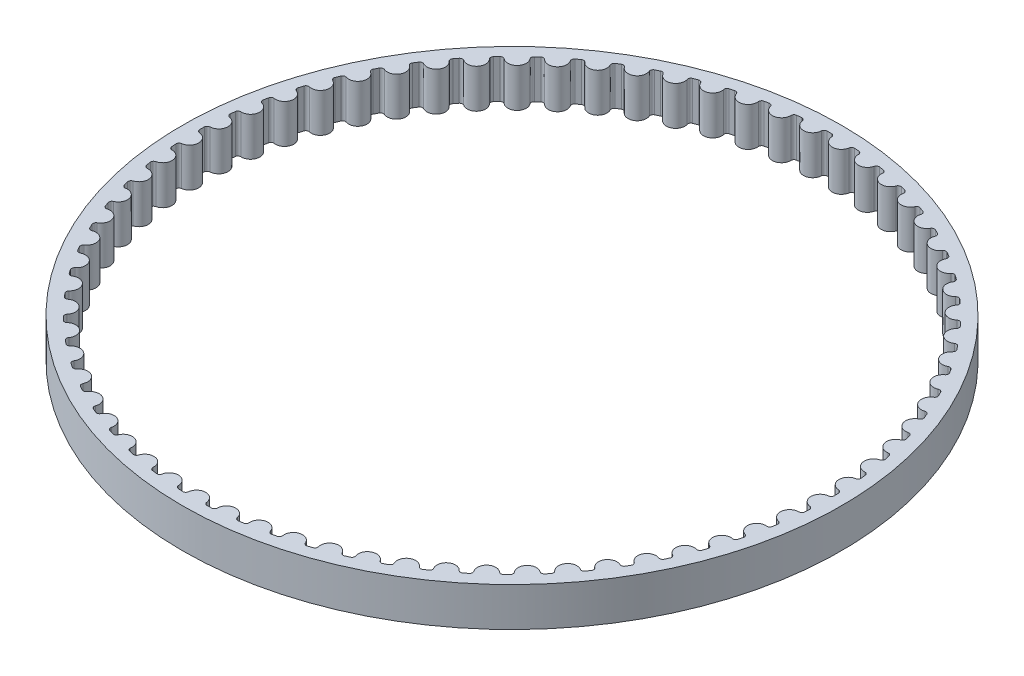
from build123d import *

# Parameters (mm, degrees)
SKETCH1_R           = 33.82407322
BOSS_EXTRUDE1_DEPTH = 4


with BuildPart() as part:
    # Sketch1 → Boss-Extrude1 (new body)
    with BuildSketch(Plane(origin=(0, 0, 0), x_dir=(1, 0, 0), z_dir=(0, 1, 0))):
        Circle(SKETCH1_R)
        with BuildLine():
            ThreePointArc((-1.716913826, -32.518780291), (-1.482140739, -32.530326213), (-1.247290427, -32.540177186))
            ThreePointArc((-1.247290427, -32.540177186), (-1.040267467, -32.467567313), (-0.938533524, -32.273194207))
            ThreePointArc((-0.938533524, -32.273194207), (0, -31.42968704), (0.938533524, -32.273194207))
            ThreePointArc((0.938533524, -32.273194207), (1.040267467, -32.467567313), (1.247290427, -32.540177186))
            ThreePointArc((1.247290427, -32.540177186), (1.482140739, -32.530326213), (1.716913826, -32.518780291))
            ThreePointArc((1.716913826, -32.518780291), (1.916476288, -32.427645647), (2.00011344, -32.224826698))
            ThreePointArc((2.00011344, -32.224826698), (2.858054263, -31.299468897), (3.869403503, -32.054135865))
            ThreePointArc((3.869403503, -32.054135865), (3.988391238, -32.23845249), (4.201159238, -32.291935924))
            ThreePointArc((4.201159238, -32.291935924), (4.434140731, -32.260769685), (4.66689119, -32.227922541))
            ThreePointArc((4.66689119, -32.227922541), (4.857339517, -32.119018298), (4.922186834, -31.909434126))
            ThreePointArc((4.922186834, -31.909434126), (5.692425789, -30.909893498), (6.768210386, -31.569466857))
            ThreePointArc((6.768210386, -31.569466857), (6.903465944, -31.742199696), (7.120215921, -31.776113512))
            ThreePointArc((7.120215921, -31.776113512), (7.349398037, -31.723890259), (7.578197223, -31.670014075))
            ThreePointArc((7.578197223, -31.670014075), (7.757953301, -31.544242647), (7.803473437, -31.329629934))
            ThreePointArc((7.803473437, -31.329629934), (8.479628082, -30.264188986), (9.610933747, -30.823203305))
            ThreePointArc((9.610933747, -30.823203305), (9.761336356, -30.98292104), (9.980272252, -30.996984216))
            ThreePointArc((9.980272252, -30.996984216), (10.203755917, -30.924136688), (10.426707928, -30.849677899))
            ThreePointArc((10.426707928, -30.849677899), (10.59428224, -30.708081467), (10.620098002, -30.490218561))
            ThreePointArc((10.620098002, -30.490218561), (11.196565506, -29.367705874), (12.374017883, -29.821528984))
            ThreePointArc((12.374017883, -29.821528984), (12.538321261, -29.966908141), (12.757628904, -29.961004146))
            ThreePointArc((12.757628904, -29.961004146), (12.973562261, -29.86813598), (13.188819647, -29.773711576))
            ThreePointArc((13.188819647, -29.773711576), (13.342823621, -29.617463454), (13.34872109, -29.398155635))
            ThreePointArc((13.34872109, -29.398155635), (13.820724662, -28.227872701), (15.034567011, -28.572744081))
            ThreePointArc((15.034567011, -28.572744081), (15.211409687, -28.702580005), (15.429271825, -28.67675776))
            ThreePointArc((15.429271825, -28.67675776), (15.635865582, -28.564638492), (15.841644653, -28.451030902))
            ThreePointArc((15.841644653, -28.451030902), (15.980802162, -28.28142581), (15.966732472, -28.062490333))
            ThreePointArc((15.966732472, -28.062490333), (16.33036094, -26.854134486), (17.570534981, -27.087196422))
            ThreePointArc((17.570534981, -27.087196422), (17.758451582, -27.200413251), (17.973062941, -27.154886728))
            ThreePointArc((17.973062941, -27.154886728), (18.168605197, -27.024445413), (18.363200802, -26.892596025))
            ThreePointArc((18.363200802, -26.892596025), (18.486358745, -26.711039365), (18.452438479, -26.494290397))
            ThreePointArc((18.452438479, -26.494290397), (18.704678705, -25.257874454), (19.960907964, -25.377195722))
            ThreePointArc((19.960907964, -25.377195722), (20.158341355, -25.472855306), (20.367923596, -25.408001752))
            ThreePointArc((20.367923596, -25.408001752), (20.550794027, -25.260319268), (20.732593687, -25.111320629))
            ThreePointArc((20.732593687, -25.111320629), (20.838731536, -24.919316836), (20.78524177, -24.706550428))
            ThreePointArc((20.78524177, -24.706550428), (20.924003612, -23.45231972), (22.185878578, -23.456911587))
            ThreePointArc((22.185878578, -23.456911587), (22.391192762, -23.53422126), (22.594009223, -23.450578072))
            ThreePointArc((22.594009223, -23.450578072), (22.762692506, -23.286878162), (22.93018977, -23.121964921))
            ThreePointArc((22.93018977, -23.121964921), (23.018428035, -22.921104999), (22.945812002, -22.7140842))
            ThreePointArc((22.945812002, -22.7140842), (22.969945635, -21.452431679), (24.227010015, -21.342256095))
            ThreePointArc((24.227010015, -21.342256095), (24.438503694, -21.400575244), (24.632873773, -21.298835517))
            ThreePointArc((24.632873773, -21.298835517), (24.785972146, -21.12047465), (24.937779079, -20.94101333))
            ThreePointArc((24.937779079, -20.94101333), (25.00738659, -20.732961668), (24.916246009, -20.533401918))
            ThreePointArc((24.916246009, -20.533401918), (24.825551454, -19.274782033), (26.067388817, -19.050751947))
            ThreePointArc((26.067388817, -19.050751947), (26.283309488, -19.089597323), (26.467622573, -18.970604103))
            ThreePointArc((26.467622573, -18.970604103), (26.603867415, -18.779060234), (26.738726097, -18.586537907))
            ThreePointArc((26.738726097, -18.586537907), (26.789126064, -18.373018487), (26.680216154, -18.1825734))
            ThreePointArc((26.680216154, -18.1825734), (26.475444935, -16.937415473), (27.691765026, -16.601387269))
            ThreePointArc((27.691765026, -16.601387269), (27.910323502, -16.620436986), (28.083052317, -16.485176289))
            ThreePointArc((28.083052317, -16.485176289), (28.201314659, -16.28203661), (28.31810761, -16.078048578))
            ThreePointArc((28.31810761, -16.078048578), (28.348882403, -15.860830688), (28.223105626, -15.681078353))
            ThreePointArc((28.223105626, -15.681078353), (27.905954542, -14.459700154), (29.086678548, -14.014458268))
            ThreePointArc((29.086678548, -14.014458268), (29.306063786, -14.013554473), (29.465777045, -13.863147112))
            ThreePointArc((29.465777045, -13.863147112), (29.565076929, -13.650094903), (29.662836365, -13.436331474))
            ThreePointArc((29.662836365, -13.436331474), (29.673730974, -13.217215051), (29.532129556, -13.049644952))
            ThreePointArc((29.532129556, -13.049644952), (29.10522662, -11.862167205), (30.240570691, -11.311401052))
            ThreePointArc((30.240570691, -11.311401052), (30.458964795, -11.290551235), (30.604339064, -11.126243532))
            ThreePointArc((30.604339064, -11.126243532), (30.68385366, -10.905044211), (30.761769515, -10.683276697))
            ThreePointArc((30.761769515, -10.683276697), (30.752693664, -10.464077407), (30.59644096, -10.310078083))
            ThreePointArc((30.59644096, -10.310078083), (30.063323625, -9.166340603), (31.143879942, -8.514614004))
            ThreePointArc((31.143879942, -8.514614004), (31.35947323, -8.473990934), (31.489303892, -8.297144394))
            ThreePointArc((31.489303892, -8.297144394), (31.548374317, -8.069630888), (31.605800955, -7.841696924))
            ThreePointArc((31.605800955, -7.841696924), (31.57682985, -7.624231123), (31.407220618, -7.485078661))
            ThreePointArc((31.407220618, -7.485078661), (30.772306461, -6.394558817), (31.789121195, -5.647272183))
            ThreePointArc((31.789121195, -5.647272183), (32.000127193, -5.587212475), (32.11333843, -5.399292505))
            ThreePointArc((32.11333843, -5.399292505), (32.151475208, -5.167350062), (32.187936775, -4.935138381))
            ThreePointArc((32.187936775, -4.935138381), (32.139310479, -4.721208058), (31.957750154, -4.598055519))
            ThreePointArc((31.957750154, -4.598055519), (31.226300276, -3.569789701), (32.170947779, -2.733135286))
            ThreePointArc((32.170947779, -2.733135286), (32.375618024, -2.654136614), (32.471271733, -2.456700377))
            ThreePointArc((32.471271733, -2.456700377), (32.488158849, -2.222250946), (32.503353214, -1.987685727))
            ThreePointArc((32.503353214, -1.987685727), (32.43547466, -1.779063577), (32.243467709, -1.672931441))
            ThreePointArc((32.243467709, -1.672931441), (31.421543131, -0.715440185), (32.286195757, 0.20364923))
            ThreePointArc((32.286195757, 0.20364923), (32.482834288, 0.300932259), (32.560137851, 0.506248743))
            ThreePointArc((32.560137851, 0.506248743), (32.555635375, 0.741262442), (32.549436631, 0.976237518))
            ThreePointArc((32.549436631, 0.976237518), (32.462868282, 1.177822786), (32.262005735, 1.266055074))
            ThreePointArc((32.262005735, 1.266055074), (31.356417185, 2.144837695), (32.13391015, 3.138746245))
            ThreePointArc((32.13391015, 3.138746245), (32.320887557, 3.253507513), (32.379200413, 3.465002927))
            ThreePointArc((32.379200413, 3.465002927), (32.353345653, 3.698633495), (32.325805165, 3.93207135))
            ThreePointArc((32.325805165, 3.93207135), (32.221264354, 4.124949338), (32.013210621, 4.194550658))
            ThreePointArc((32.013210621, 4.194550658), (31.03146209, 4.987342774), (31.715352842, 6.04783462))
            ThreePointArc((31.715352842, 6.04783462), (31.891119772, 6.179123179), (31.929958723, 6.395045006))
            ThreePointArc((31.929958723, 6.395045006), (31.88296592, 6.625356506), (31.834311897, 6.855322801))
            ThreePointArc((31.834311897, 6.855322801), (31.712664882, 7.037895261), (31.499143962, 7.088288874))
            ThreePointArc((31.499143962, 7.088288874), (30.449370528, 7.78852116), (31.033992133, 8.906808733))
            ThreePointArc((31.033992133, 8.906808733), (31.197092126, 9.053536684), (31.216135339, 9.272095727))
            ThreePointArc((31.216135339, 9.272095727), (31.14839389, 9.497179727), (31.079029495, 9.721768888))
            ThreePointArc((31.079029495, 9.721768888), (30.941284281, 9.892522967), (30.724065475, 9.923291296))
            ThreePointArc((30.724065475, 9.923291296), (29.614965892, 10.525161407), (30.095473991, 11.691978223))
            ThreePointArc((30.095473991, 11.691978223), (30.244555549, 11.852929733), (30.243645226, 12.072314944))
            ThreePointArc((30.243645226, 12.072314944), (30.155716458, 12.290306325), (30.066216467, 12.507657337))
            ThreePointArc((30.066216467, 12.507657337), (29.913514454, 12.665178112), (29.694397706, 12.676066201))
            ThreePointArc((29.694397706, 12.676066201), (28.535162322, 13.174586851), (28.907575273, 14.3802643))
            ThreePointArc((28.907575273, 14.3802643), (29.04140306, 14.554105673), (29.020546745, 14.772499156))
            ThreePointArc((29.020546745, 14.772499156), (28.913159263, 14.981591575), (28.8042653, 15.189903397))
            ThreePointArc((28.8042653, 15.189903397), (28.637871825, 15.332885603), (28.418672806, 15.32380323))
            ThreePointArc((28.418672806, 15.32380323), (27.218907409, 15.71484352), (27.480139283, 16.949390977))
            ThreePointArc((27.480139283, 16.949390977), (27.597604358, 17.13468171), (27.556974873, 17.350273788))
            ThreePointArc((27.556974873, 17.350273788), (27.431018524, 17.548734638), (27.303632919, 17.746281135))
            ThreePointArc((27.303632919, 17.746281135), (27.124926772, 17.873539975), (26.907461833, 17.844562398))
            ThreePointArc((26.907461833, 17.844562398), (25.677108058, 18.124882046), (25.824994204, 19.378069663))
            ThreePointArc((25.824994204, 19.378069663), (25.925123216, 19.573274377), (25.865057229, 19.784278588))
            ThreePointArc((25.865057229, 19.784278588), (25.721575727, 19.97046336), (25.576754037, 20.155607597))
            ThreePointArc((25.576754037, 20.155607597), (25.387216032, 20.266088565), (25.173287157, 20.217455903))
            ThreePointArc((25.173287157, 20.217455903), (23.922540103, 20.384732091), (23.955855089, 21.646175561))
            ThreePointArc((23.955855089, 21.646175561), (24.037818337, 21.849676729), (23.958813574, 22.054344624))
            ThreePointArc((23.958813574, 22.054344624), (23.798995853, 22.226710532), (23.637938116, 22.397918348))
            ThreePointArc((23.637938116, 22.397918348), (23.439138825, 22.490705963), (23.230518695, 22.422821201))
            ThreePointArc((23.230518695, 22.422821201), (21.969742446, 22.475667827), (21.888210215, 23.734914431))
            ThreePointArc((21.888210215, 23.734914431), (21.951328526, 23.945025779), (21.854039645, 24.141661415))
            ThreePointArc((21.854039645, 24.141661415), (21.679210003, 24.298780182), (21.503250795, 24.454632893))
            ThreePointArc((21.503250795, 24.454632893), (21.296837532, 24.528958289), (21.09525484, 24.442383941))
            ThreePointArc((21.09525484, 24.442383941), (19.834896585, 24.3803631), (19.639192738, 25.626978325))
            ThreePointArc((19.639192738, 25.626978325), (19.682943093, 25.841958803), (19.568176261, 26.028932796))
            ThreePointArc((19.568176261, 26.028932796), (19.379783392, 26.169502486), (19.190380766, 26.308708648))
            ThreePointArc((19.190380766, 26.308708648), (18.978063936, 26.363955941), (18.785189059, 26.25940939))
            ThreePointArc((18.785189059, 26.25940939), (17.535692523, 26.083035006), (17.227438724, 27.306689006))
            ThreePointArc((17.227438724, 27.306689006), (17.251458595, 27.524757219), (17.120164806, 27.700520242))
            ThreePointArc((17.120164806, 27.700520242), (16.919769793, 27.82337605), (16.718493198, 27.944782158))
            ThreePointArc((16.718493198, 27.944782158), (16.502032125, 27.98049355), (16.319463285, 27.858841102))
            ThreePointArc((16.319463285, 27.858841102), (15.091182191, 27.56957467), (14.672932728, 28.760127862))
            ThreePointArc((14.672932728, 28.760127862), (14.677023077, 28.979476827), (14.530290273, 29.142572454))
            ThreePointArc((14.530290273, 29.142572454), (14.319553652, 29.246696358), (14.10807093, 29.349296402))
            ThreePointArc((14.10807093, 29.349296402), (13.889259279, 29.365175979), (13.7185093, 29.227425684))
            ThreePointArc((13.7185093, 29.227425684), (12.52162157, 28.827664156), (11.99684219, 29.975251241))
            ThreePointArc((11.99684219, 29.975251241), (11.980969125, 30.194063364), (11.820013179, 30.343140133))
            ThreePointArc((11.820013179, 30.343140133), (11.60068118, 30.42766933), (11.380744744, 30.510613133))
            ThreePointArc((11.380744744, 30.510613133), (11.161395657, 30.506529311), (11.003879425, 30.353822611))
            ThreePointArc((11.003879425, 30.353822611), (9.84830285, 29.846878537), (9.221342039, 30.941990248))
            ThreePointArc((9.221342039, 30.941990248), (9.185637088, 31.158452383), (9.011791733, 31.292274996))
            ThreePointArc((9.011791733, 31.292274996), (8.78568181, 31.35650905), (8.559114122, 31.419109315))
            ThreePointArc((8.559114122, 31.419109315), (8.341045195, 31.395095933), (8.19806794, 31.228698204))
            ThreePointArc((8.19806794, 31.228698204), (7.09337799, 30.618772283), (6.369430945, 31.652334178))
            ThreePointArc((6.369430945, 31.652334178), (6.31418997, 31.864652652), (6.128895743, 31.982112214))
            ThreePointArc((6.128895743, 31.982112214), (5.897881514, 32.025518861), (5.666559985, 32.067256861))
            ThreePointArc((5.666559985, 32.067256861), (5.451578205, 32.023512903), (5.324324683, 31.844802969))
            ThreePointArc((5.324324683, 31.844802969), (4.279675166, 31.136949239), (3.464740739, 32.100396899))
            ThreePointArc((3.464740739, 32.100396899), (3.390421485, 32.306812374), (3.195213792, 32.406935577))
            ThreePointArc((3.195213792, 32.406935577), (2.961209514, 32.429155137), (2.727050947, 32.449685019))
            ThreePointArc((2.727050947, 32.449685019), (2.516937722, 32.38657296), (2.406462394, 32.197031668))
            ThreePointArc((2.406462394, 32.197031668), (1.430509606, 31.397115627), (0.5313406, 32.282465622))
            ThreePointArc((0.5313406, 32.282465622), (0.4385589, 32.481267674), (0.235055293, 32.563224866))
            ThreePointArc((0.235055293, 32.563224866), (0, 32.56407322), (-0.235055293, 32.563224866))
            ThreePointArc((-0.235055293, 32.563224866), (-0.4385589, 32.481267674), (-0.5313406, 32.282465622))
            ThreePointArc((-0.5313406, 32.282465622), (-1.430509606, 31.397115627), (-2.406462394, 32.197031668))
            ThreePointArc((-2.406462394, 32.197031668), (-2.516937722, 32.38657296), (-2.727050947, 32.449685019))
            ThreePointArc((-2.727050947, 32.449685019), (-2.961209514, 32.429155137), (-3.195213792, 32.406935577))
            ThreePointArc((-3.195213792, 32.406935577), (-3.390421485, 32.306812374), (-3.464740739, 32.100396899))
            ThreePointArc((-3.464740739, 32.100396899), (-4.279675166, 31.136949239), (-5.324324683, 31.844802969))
            ThreePointArc((-5.324324683, 31.844802969), (-5.451578205, 32.023512903), (-5.666559985, 32.067256861))
            ThreePointArc((-5.666559985, 32.067256861), (-5.897881514, 32.025518861), (-6.128895743, 31.982112214))
            ThreePointArc((-6.128895743, 31.982112214), (-6.31418997, 31.864652652), (-6.369430945, 31.652334178))
            ThreePointArc((-6.369430945, 31.652334178), (-7.09337799, 30.618772283), (-8.19806794, 31.228698204))
            ThreePointArc((-8.19806794, 31.228698204), (-8.341045195, 31.395095933), (-8.559114122, 31.419109315))
            ThreePointArc((-8.559114122, 31.419109315), (-8.78568181, 31.35650905), (-9.011791733, 31.292274996))
            ThreePointArc((-9.011791733, 31.292274996), (-9.185637088, 31.158452383), (-9.221342039, 30.941990248))
            ThreePointArc((-9.221342039, 30.941990248), (-9.84830285, 29.846878537), (-11.003879425, 30.353822611))
            ThreePointArc((-11.003879425, 30.353822611), (-11.161395657, 30.506529311), (-11.380744744, 30.510613133))
            ThreePointArc((-11.380744744, 30.510613133), (-11.60068118, 30.42766933), (-11.820013179, 30.343140133))
            ThreePointArc((-11.820013179, 30.343140133), (-11.980969125, 30.194063364), (-11.99684219, 29.975251241))
            ThreePointArc((-11.99684219, 29.975251241), (-12.52162157, 28.827664156), (-13.7185093, 29.227425684))
            ThreePointArc((-13.7185093, 29.227425684), (-13.889259279, 29.365175979), (-14.10807093, 29.349296402))
            ThreePointArc((-14.10807093, 29.349296402), (-14.319553652, 29.246696358), (-14.530290273, 29.142572454))
            ThreePointArc((-14.530290273, 29.142572454), (-14.677023077, 28.979476827), (-14.672932728, 28.760127862))
            ThreePointArc((-14.672932728, 28.760127862), (-15.091182191, 27.56957467), (-16.319463285, 27.858841102))
            ThreePointArc((-16.319463285, 27.858841102), (-16.502032125, 27.98049355), (-16.718493198, 27.944782158))
            ThreePointArc((-16.718493198, 27.944782158), (-16.919769793, 27.82337605), (-17.120164806, 27.700520242))
            ThreePointArc((-17.120164806, 27.700520242), (-17.251458595, 27.524757219), (-17.227438724, 27.306689006))
            ThreePointArc((-17.227438724, 27.306689006), (-17.535692523, 26.083035006), (-18.785189059, 26.25940939))
            ThreePointArc((-18.785189059, 26.25940939), (-18.978063936, 26.363955941), (-19.190380766, 26.308708648))
            ThreePointArc((-19.190380766, 26.308708648), (-19.379783392, 26.169502486), (-19.568176261, 26.028932796))
            ThreePointArc((-19.568176261, 26.028932796), (-19.682943093, 25.841958803), (-19.639192738, 25.626978325))
            ThreePointArc((-19.639192738, 25.626978325), (-19.834896585, 24.3803631), (-21.09525484, 24.442383941))
            ThreePointArc((-21.09525484, 24.442383941), (-21.296837532, 24.528958289), (-21.503250795, 24.454632893))
            ThreePointArc((-21.503250795, 24.454632893), (-21.679210003, 24.298780182), (-21.854039645, 24.141661415))
            ThreePointArc((-21.854039645, 24.141661415), (-21.951328526, 23.945025779), (-21.888210215, 23.734914431))
            ThreePointArc((-21.888210215, 23.734914431), (-21.969742446, 22.475667827), (-23.230518695, 22.422821201))
            ThreePointArc((-23.230518695, 22.422821201), (-23.439138825, 22.490705963), (-23.637938116, 22.397918348))
            ThreePointArc((-23.637938116, 22.397918348), (-23.798995853, 22.226710532), (-23.958813574, 22.054344624))
            ThreePointArc((-23.958813574, 22.054344624), (-24.037818337, 21.849676729), (-23.955855089, 21.646175561))
            ThreePointArc((-23.955855089, 21.646175561), (-23.922540103, 20.384732091), (-25.173287157, 20.217455903))
            ThreePointArc((-25.173287157, 20.217455903), (-25.387216032, 20.266088565), (-25.576754037, 20.155607597))
            ThreePointArc((-25.576754037, 20.155607597), (-25.721575727, 19.97046336), (-25.865057229, 19.784278588))
            ThreePointArc((-25.865057229, 19.784278588), (-25.925123216, 19.573274377), (-25.824994204, 19.378069663))
            ThreePointArc((-25.824994204, 19.378069663), (-25.677108058, 18.124882046), (-26.907461833, 17.844562398))
            ThreePointArc((-26.907461833, 17.844562398), (-27.124926772, 17.873539975), (-27.303632919, 17.746281135))
            ThreePointArc((-27.303632919, 17.746281135), (-27.431018524, 17.548734638), (-27.556974873, 17.350273788))
            ThreePointArc((-27.556974873, 17.350273788), (-27.597604358, 17.13468171), (-27.480139283, 16.949390977))
            ThreePointArc((-27.480139283, 16.949390977), (-27.218907409, 15.71484352), (-28.418672806, 15.32380323))
            ThreePointArc((-28.418672806, 15.32380323), (-28.637871825, 15.332885603), (-28.8042653, 15.189903397))
            ThreePointArc((-28.8042653, 15.189903397), (-28.913159263, 14.981591575), (-29.020546745, 14.772499156))
            ThreePointArc((-29.020546745, 14.772499156), (-29.04140306, 14.554105673), (-28.907575273, 14.3802643))
            ThreePointArc((-28.907575273, 14.3802643), (-28.535162322, 13.174586851), (-29.694397706, 12.676066201))
            ThreePointArc((-29.694397706, 12.676066201), (-29.913514454, 12.665178112), (-30.066216467, 12.507657337))
            ThreePointArc((-30.066216467, 12.507657337), (-30.155716458, 12.290306325), (-30.243645226, 12.072314944))
            ThreePointArc((-30.243645226, 12.072314944), (-30.244555549, 11.852929733), (-30.095473991, 11.691978223))
            ThreePointArc((-30.095473991, 11.691978223), (-29.614965892, 10.525161407), (-30.724065475, 9.923291296))
            ThreePointArc((-30.724065475, 9.923291296), (-30.941284281, 9.892522967), (-31.079029495, 9.721768888))
            ThreePointArc((-31.079029495, 9.721768888), (-31.14839389, 9.497179727), (-31.216135339, 9.272095727))
            ThreePointArc((-31.216135339, 9.272095727), (-31.197092126, 9.053536684), (-31.033992133, 8.906808733))
            ThreePointArc((-31.033992133, 8.906808733), (-30.449370528, 7.78852116), (-31.499143962, 7.088288874))
            ThreePointArc((-31.499143962, 7.088288874), (-31.712664882, 7.037895261), (-31.834311897, 6.855322801))
            ThreePointArc((-31.834311897, 6.855322801), (-31.88296592, 6.625356506), (-31.929958723, 6.395045006))
            ThreePointArc((-31.929958723, 6.395045006), (-31.891119772, 6.179123179), (-31.715352842, 6.04783462))
            ThreePointArc((-31.715352842, 6.04783462), (-31.03146209, 4.987342774), (-32.013210621, 4.194550658))
            ThreePointArc((-32.013210621, 4.194550658), (-32.221264354, 4.124949338), (-32.325805165, 3.93207135))
            ThreePointArc((-32.325805165, 3.93207135), (-32.353345653, 3.698633495), (-32.379200413, 3.465002927))
            ThreePointArc((-32.379200413, 3.465002927), (-32.320887557, 3.253507513), (-32.13391015, 3.138746245))
            ThreePointArc((-32.13391015, 3.138746245), (-31.356417185, 2.144837695), (-32.262005735, 1.266055074))
            ThreePointArc((-32.262005735, 1.266055074), (-32.462868282, 1.177822786), (-32.549436631, 0.976237518))
            ThreePointArc((-32.549436631, 0.976237518), (-32.555635375, 0.741262442), (-32.560137851, 0.506248743))
            ThreePointArc((-32.560137851, 0.506248743), (-32.482834288, 0.300932259), (-32.286195757, 0.20364923))
            ThreePointArc((-32.286195757, 0.20364923), (-31.421543131, -0.715440185), (-32.243467709, -1.672931441))
            ThreePointArc((-32.243467709, -1.672931441), (-32.43547466, -1.779063577), (-32.503353214, -1.987685727))
            ThreePointArc((-32.503353214, -1.987685727), (-32.488158849, -2.222250946), (-32.471271733, -2.456700377))
            ThreePointArc((-32.471271733, -2.456700377), (-32.375618024, -2.654136614), (-32.170947779, -2.733135286))
            ThreePointArc((-32.170947779, -2.733135286), (-31.226300276, -3.569789701), (-31.957750154, -4.598055519))
            ThreePointArc((-31.957750154, -4.598055519), (-32.139310479, -4.721208058), (-32.187936775, -4.935138381))
            ThreePointArc((-32.187936775, -4.935138381), (-32.151475208, -5.167350062), (-32.11333843, -5.399292505))
            ThreePointArc((-32.11333843, -5.399292505), (-32.000127193, -5.587212475), (-31.789121195, -5.647272183))
            ThreePointArc((-31.789121195, -5.647272183), (-30.772306461, -6.394558817), (-31.407220618, -7.485078661))
            ThreePointArc((-31.407220618, -7.485078661), (-31.57682985, -7.624231123), (-31.605800955, -7.841696924))
            ThreePointArc((-31.605800955, -7.841696924), (-31.548374317, -8.069630888), (-31.489303892, -8.297144394))
            ThreePointArc((-31.489303892, -8.297144394), (-31.35947323, -8.473990934), (-31.143879942, -8.514614004))
            ThreePointArc((-31.143879942, -8.514614004), (-30.063323625, -9.166340603), (-30.59644096, -10.310078083))
            ThreePointArc((-30.59644096, -10.310078083), (-30.752693664, -10.464077407), (-30.761769515, -10.683276697))
            ThreePointArc((-30.761769515, -10.683276697), (-30.68385366, -10.905044211), (-30.604339064, -11.126243532))
            ThreePointArc((-30.604339064, -11.126243532), (-30.458964795, -11.290551235), (-30.240570691, -11.311401052))
            ThreePointArc((-30.240570691, -11.311401052), (-29.10522662, -11.862167205), (-29.532129556, -13.049644952))
            ThreePointArc((-29.532129556, -13.049644952), (-29.673730974, -13.217215051), (-29.662836365, -13.436331474))
            ThreePointArc((-29.662836365, -13.436331474), (-29.565076929, -13.650094903), (-29.465777045, -13.863147112))
            ThreePointArc((-29.465777045, -13.863147112), (-29.306063786, -14.013554473), (-29.086678548, -14.014458268))
            ThreePointArc((-29.086678548, -14.014458268), (-27.905954542, -14.459700154), (-28.223105626, -15.681078353))
            ThreePointArc((-28.223105626, -15.681078353), (-28.348882403, -15.860830688), (-28.31810761, -16.078048578))
            ThreePointArc((-28.31810761, -16.078048578), (-28.201314659, -16.28203661), (-28.083052317, -16.485176289))
            ThreePointArc((-28.083052317, -16.485176289), (-27.910323502, -16.620436986), (-27.691765026, -16.601387269))
            ThreePointArc((-27.691765026, -16.601387269), (-26.475444935, -16.937415473), (-26.680216154, -18.1825734))
            ThreePointArc((-26.680216154, -18.1825734), (-26.789126064, -18.373018487), (-26.738726097, -18.586537907))
            ThreePointArc((-26.738726097, -18.586537907), (-26.603867415, -18.779060234), (-26.467622573, -18.970604103))
            ThreePointArc((-26.467622573, -18.970604103), (-26.283309488, -19.089597323), (-26.067388817, -19.050751947))
            ThreePointArc((-26.067388817, -19.050751947), (-24.825551454, -19.274782033), (-24.916246009, -20.533401918))
            ThreePointArc((-24.916246009, -20.533401918), (-25.00738659, -20.732961668), (-24.937779079, -20.94101333))
            ThreePointArc((-24.937779079, -20.94101333), (-24.785972146, -21.12047465), (-24.632873773, -21.298835517))
            ThreePointArc((-24.632873773, -21.298835517), (-24.438503694, -21.400575244), (-24.227010015, -21.342256095))
            ThreePointArc((-24.227010015, -21.342256095), (-22.969945635, -21.452431679), (-22.945812002, -22.7140842))
            ThreePointArc((-22.945812002, -22.7140842), (-23.018428035, -22.921104999), (-22.93018977, -23.121964921))
            ThreePointArc((-22.93018977, -23.121964921), (-22.762692506, -23.286878162), (-22.594009223, -23.450578072))
            ThreePointArc((-22.594009223, -23.450578072), (-22.391192762, -23.53422126), (-22.185878578, -23.456911587))
            ThreePointArc((-22.185878578, -23.456911587), (-20.924003612, -23.45231972), (-20.78524177, -24.706550428))
            ThreePointArc((-20.78524177, -24.706550428), (-20.838731536, -24.919316836), (-20.732593687, -25.111320629))
            ThreePointArc((-20.732593687, -25.111320629), (-20.550794027, -25.260319268), (-20.367923596, -25.408001752))
            ThreePointArc((-20.367923596, -25.408001752), (-20.158341355, -25.472855306), (-19.960907964, -25.377195722))
            ThreePointArc((-19.960907964, -25.377195722), (-18.704678705, -25.257874454), (-18.452438479, -26.494290397))
            ThreePointArc((-18.452438479, -26.494290397), (-18.486358745, -26.711039365), (-18.363200802, -26.892596025))
            ThreePointArc((-18.363200802, -26.892596025), (-18.168605197, -27.024445413), (-17.973062941, -27.154886728))
            ThreePointArc((-17.973062941, -27.154886728), (-17.758451582, -27.200413251), (-17.570534981, -27.087196422))
            ThreePointArc((-17.570534981, -27.087196422), (-16.33036094, -26.854134486), (-15.966732472, -28.062490333))
            ThreePointArc((-15.966732472, -28.062490333), (-15.980802162, -28.28142581), (-15.841644653, -28.451030902))
            ThreePointArc((-15.841644653, -28.451030902), (-15.635865582, -28.564638492), (-15.429271825, -28.67675776))
            ThreePointArc((-15.429271825, -28.67675776), (-15.211409687, -28.702580005), (-15.034567011, -28.572744081))
            ThreePointArc((-15.034567011, -28.572744081), (-13.820724662, -28.227872701), (-13.34872109, -29.398155635))
            ThreePointArc((-13.34872109, -29.398155635), (-13.342823621, -29.617463454), (-13.188819647, -29.773711576))
            ThreePointArc((-13.188819647, -29.773711576), (-12.973562261, -29.86813598), (-12.757628904, -29.961004146))
            ThreePointArc((-12.757628904, -29.961004146), (-12.538321261, -29.966908141), (-12.374017883, -29.821528984))
            ThreePointArc((-12.374017883, -29.821528984), (-11.196565506, -29.367705874), (-10.620098002, -30.490218561))
            ThreePointArc((-10.620098002, -30.490218561), (-10.59428224, -30.708081467), (-10.426707928, -30.849677899))
            ThreePointArc((-10.426707928, -30.849677899), (-10.203755917, -30.924136688), (-9.980272252, -30.996984216))
            ThreePointArc((-9.980272252, -30.996984216), (-9.761336356, -30.98292104), (-9.610933747, -30.823203305))
            ThreePointArc((-9.610933747, -30.823203305), (-8.479628082, -30.264188986), (-7.803473437, -31.329629934))
            ThreePointArc((-7.803473437, -31.329629934), (-7.757953301, -31.544242647), (-7.578197223, -31.670014075))
            ThreePointArc((-7.578197223, -31.670014075), (-7.349398037, -31.723890259), (-7.120215921, -31.776113512))
            ThreePointArc((-7.120215921, -31.776113512), (-6.903465944, -31.742199696), (-6.768210386, -31.569466857))
            ThreePointArc((-6.768210386, -31.569466857), (-5.692425789, -30.909893498), (-4.922186834, -31.909434126))
            ThreePointArc((-4.922186834, -31.909434126), (-4.857339517, -32.119018298), (-4.66689119, -32.227922541))
            ThreePointArc((-4.66689119, -32.227922541), (-4.434140731, -32.260769685), (-4.201159238, -32.291935924))
            ThreePointArc((-4.201159238, -32.291935924), (-3.988391238, -32.23845249), (-3.869403503, -32.054135865))
            ThreePointArc((-3.869403503, -32.054135865), (-2.858054263, -31.299468897), (-2.00011344, -32.224826698))
            ThreePointArc((-2.00011344, -32.224826698), (-1.916476288, -32.427645647), (-1.716913826, -32.518780291))
        make_face(mode=Mode.SUBTRACT)
    extrude(amount=BOSS_EXTRUDE1_DEPTH)


solid = part.part
